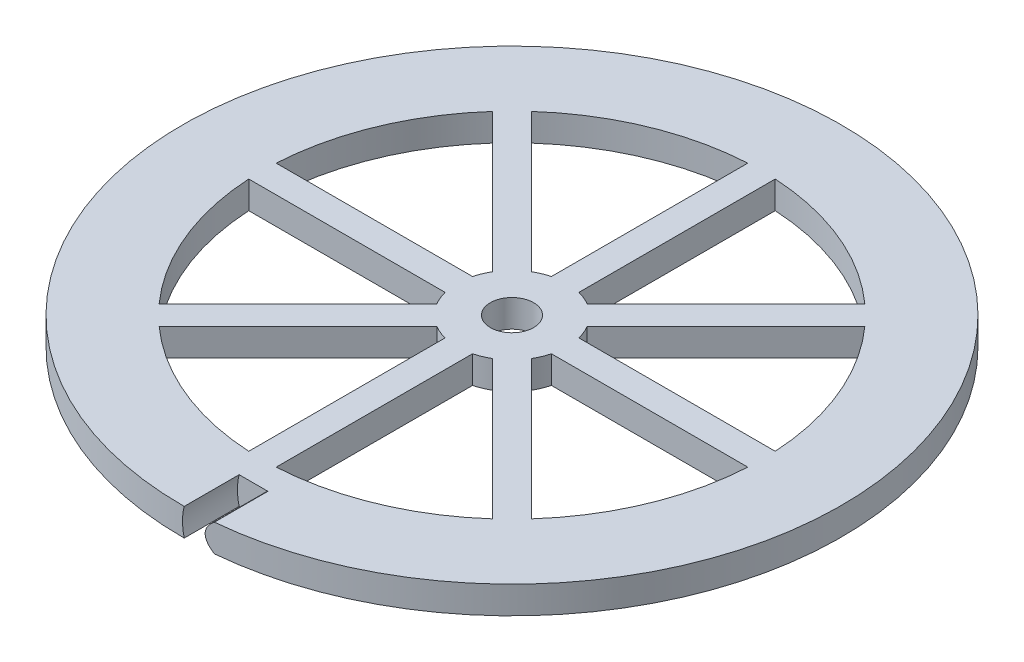
from build123d import *

# Parameters (mm, degrees)
SKETCH1_R           = 76.2
SKETCH1_R_2         = 57.785
SKETCH1_R_3         = 12.7
SKETCH1_R_4         = 5
BOSS_EXTRUDE1_DEPTH = 3.175
CUT_EXTRUDE1_DEPTH  = 12.7


with BuildPart() as part:
    # Sketch1 → Boss-Extrude1 (new body, symmetric)
    with BuildSketch(Plane(origin=(0, 0, 0), x_dir=(1, 0, 0), z_dir=(0, 1, 0))):
        Circle(SKETCH1_R)
        Circle(SKETCH1_R_2, mode=Mode.SUBTRACT)
        with BuildLine():
            Line((-6.45003157, 10.940159631), (-38.553377116, 43.043505177))
            ThreePointArc((-38.553377116, 43.043505177), (-40.860165351, 40.860165351), (-43.043505177, 38.553377116))
            Line((-43.043505177, 38.553377116), (-10.940159631, 6.45003157))
            ThreePointArc((-10.940159631, 6.45003157), (-8.980256121, 8.980256121), (-6.45003157, 10.940159631))
        make_face()
        with BuildLine():
            Line((-12.296722124, 3.175), (-57.697708793, 3.175))
            ThreePointArc((-57.697708793, 3.175), (-57.785, 0), (-57.697708793, -3.175))
            Line((-57.697708793, -3.175), (-12.296722124, -3.175))
            ThreePointArc((-12.296722124, -3.175), (-12.7, 0), (-12.296722124, 3.175))
        make_face()
        with BuildLine():
            Line((-10.940159631, -6.45003157), (-43.043505177, -38.553377116))
            ThreePointArc((-43.043505177, -38.553377116), (-40.860165351, -40.860165351), (-38.553377116, -43.043505177))
            Line((-38.553377116, -43.043505177), (-6.45003157, -10.940159631))
            ThreePointArc((-6.45003157, -10.940159631), (-8.980256121, -8.980256121), (-10.940159631, -6.45003157))
        make_face()
        Circle(SKETCH1_R_3)
        Circle(SKETCH1_R_4, mode=Mode.SUBTRACT)
        with BuildLine():
            Line((-3.175, -12.296722124), (-3.175, -57.697708793))
            ThreePointArc((-3.175, -57.697708793), (0, -57.785), (3.175, -57.697708793))
            Line((3.175, -57.697708793), (3.175, -12.296722124))
            ThreePointArc((3.175, -12.296722124), (0, -12.7), (-3.175, -12.296722124))
        make_face()
        with BuildLine():
            ThreePointArc((38.553377116, -43.043505177), (40.860165351, -40.860165351), (43.043505177, -38.553377116))
            Line((43.043505177, -38.553377116), (10.940159631, -6.45003157))
            ThreePointArc((10.940159631, -6.45003157), (8.980256121, -8.980256121), (6.45003157, -10.940159631))
            Line((6.45003157, -10.940159631), (38.553377116, -43.043505177))
        make_face()
        with BuildLine():
            ThreePointArc((57.785, 0), (57.763173076, 1.588099867), (57.697708793, 3.175))
            Line((57.697708793, 3.175), (12.296722124, 3.175))
            ThreePointArc((12.296722124, 3.175), (12.598777143, 1.600254515), (12.7, 0))
            ThreePointArc((12.7, 0), (12.598777143, -1.600254515), (12.296722124, -3.175))
            Line((12.296722124, -3.175), (57.697708793, -3.175))
            ThreePointArc((57.697708793, -3.175), (57.763173076, -1.588099867), (57.785, 0))
        make_face()
        with BuildLine():
            ThreePointArc((43.043505177, 38.553377116), (40.860165351, 40.860165351), (38.553377116, 43.043505177))
            Line((38.553377116, 43.043505177), (6.45003157, 10.940159631))
            ThreePointArc((6.45003157, 10.940159631), (8.980256121, 8.980256121), (10.940159631, 6.45003157))
            Line((10.940159631, 6.45003157), (43.043505177, 38.553377116))
        make_face()
        with BuildLine():
            ThreePointArc((3.175, 57.697708793), (0, 57.785), (-3.175, 57.697708793))
            Line((-3.175, 57.697708793), (-3.175, 12.296722124))
            ThreePointArc((-3.175, 12.296722124), (0, 12.7), (3.175, 12.296722124))
            Line((3.175, 12.296722124), (3.175, 57.697708793))
        make_face()
    extrude(amount=BOSS_EXTRUDE1_DEPTH, both=True)

    # Sketch2 → Cut-Extrude1 (cut)
    with BuildSketch(Plane.XY.offset(76.2)):
        with BuildLine():
            Line((1.701477372, 6.35), (14.401477372, 6.35))
            add(Edge.make_bspline(
                [(14.401477372, 6.35), (-9.645577139, 0), (14.401477372, -6.35)],
                knots=[5.397827698, 5.397827698, 5.397827698, 7.168542916, 7.168542916, 7.168542916], degree=2, weights=[1, 0.633012702, 1]))
            Line((14.401477372, -6.35), (1.701477372, -6.35))
            ThreePointArc((1.701477372, -6.35), (0, 0), (1.701477372, 6.35))
        make_face()
    extrude(amount=-CUT_EXTRUDE1_DEPTH, mode=Mode.SUBTRACT)


solid = part.part
